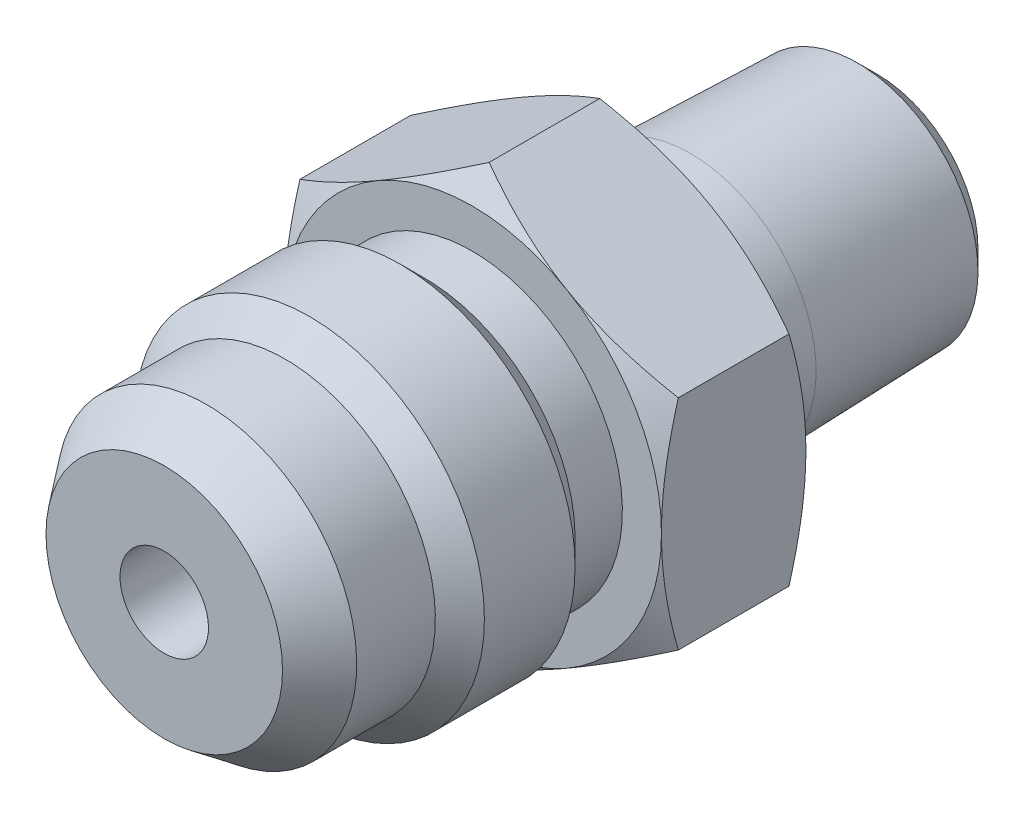
from build123d import *

# Parameters (mm, degrees)
SKETCH2_R           = 10.19175
BOSS_EXTRUDE1_DEPTH = 7.874


with BuildPart() as part:
    # Sketch1 → Revolve1 (revolve)
    with BuildSketch(Plane(origin=(0, 0, 0), x_dir=(0, 0, -1), z_dir=(1, 0, 0))):
        Polygon((-19.446875, 2.413), (-19.446875, 6.448056668), (-17.138253125, 8.187728032), (-12.8508125, 8.187728032), (-11.513540532, 9.525), (-6.568084468, 9.525), (-5.2308125, 8.187728032), (-2.651125, 8.187728032), (-2.651125, 10.31875), (5.222875, 10.31875), (5.222875, 6.858), (9.241155, 6.858), (18.354531448, 6.574254175), (19.446875, 5.481910623), (19.446875, 2.413), align=None)
    revolve(axis=Axis((0, 0, 19.446875), (0, 0, -1)))

    # Sketch2 → Boss-Extrude1 (add)
    with BuildSketch(Plane.XY.offset(2.651125)):
        Polygon((0, 11.91506618), (-10.31875, 5.95753309), (-10.31875, -5.95753309), (0, -11.91506618), (10.31875, -5.95753309), (10.31875, 5.95753309), align=None)
        Circle(SKETCH2_R, mode=Mode.SUBTRACT)
    extrude(amount=-BOSS_EXTRUDE1_DEPTH)

    # Sketch3 → Cut-Revolve1 (revolve, cut)
    with BuildSketch(Plane(origin=(0, 0, 0), x_dir=(0, 0, -1), z_dir=(1, 0, 0))):
        Polygon((-2.651125, 10.31875), (-2.651125, 11.91506618), (-1.729491424, 11.91506618), align=None)
        Polygon((4.301241424, 11.91506618), (5.222875, 10.31875), (5.222875, 11.91506618), align=None)
    revolve(axis=Axis((0, 0, 19.446875), (0, 0, -1)), mode=Mode.SUBTRACT)


solid = part.part
